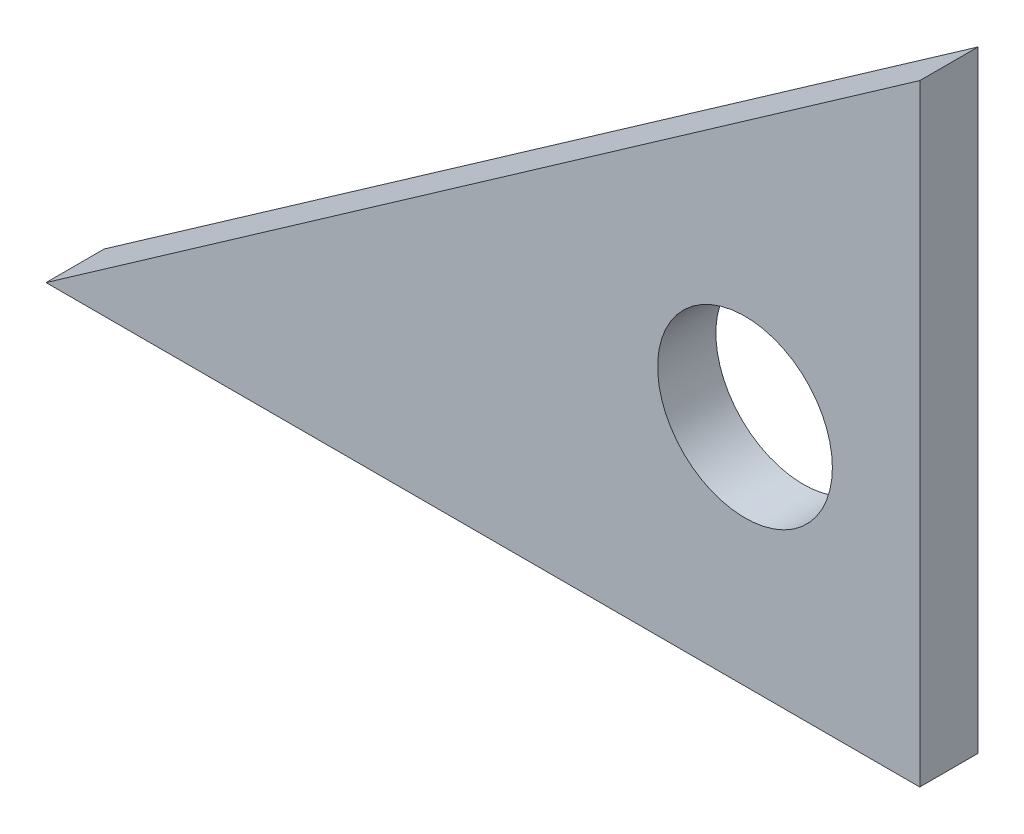
from build123d import *

# Parameters (mm, degrees)
BOSS_EXTRUDE1_DEPTH = 6.35
SKETCH2_R           = 9.525
CUT_EXTRUDE1_DEPTH  = 6.35


with BuildPart() as part:
    # Sketch1 → Boss-Extrude1 (new body)
    with BuildSketch(Plane.XY):
        Polygon((0, 0), (95.25, 66.694768014), (95.25, 0), align=None)
    extrude(amount=BOSS_EXTRUDE1_DEPTH)

    # Sketch2 → Cut-Extrude1 (cut)
    with BuildSketch(Plane.XY.offset(6.35)):
        with Locations((76.2, 25.4)):
            Circle(SKETCH2_R)
    extrude(amount=-CUT_EXTRUDE1_DEPTH, mode=Mode.SUBTRACT)


solid = part.part
